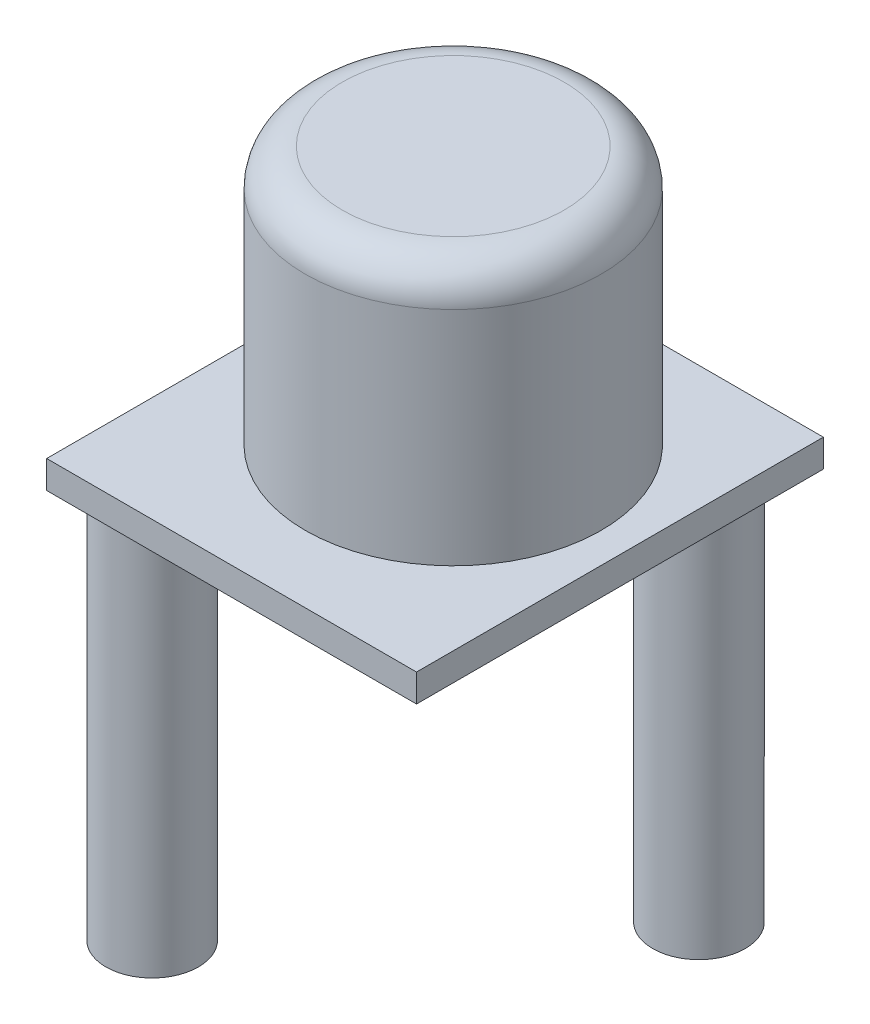
from build123d import *

# Parameters (mm, degrees)
ESBO_O1_W                = 20
ESBO_O1_H                = 22
RESSALTO_EXTRUS_O1_DEPTH = 1.5
ESBO_O2_R                = 8
RESSALTO_EXTRUS_O2_DEPTH = 14
FILETE1_R                = 2
ESBO_O3_R                = 2.5
RESSALTO_EXTRUS_O3_DEPTH = 21
ESBO_O4_W                = 8
ESBO_O4_H                = 8
RESSALTO_EXTRUS_O4_DEPTH = 10


with BuildPart() as part:
    # Esboço1 → Ressalto-extrusão1 (new body)
    with BuildSketch(Plane(origin=(0, 0, 0), x_dir=(1, 0, 0), z_dir=(0, 1, 0))):
        with Locations((-0.363033398, -2.207136461)):
            Rectangle(ESBO_O1_W, ESBO_O1_H)
    extrude(amount=RESSALTO_EXTRUS_O1_DEPTH)

    # Esboço2 → Ressalto-extrusão2 (add)
    with BuildSketch(Plane(origin=(0, 1.5, 0), x_dir=(1, 0, 0), z_dir=(0, 1, 0))):
        with Locations((0, -1.584818961)):
            Circle(ESBO_O2_R)
    extrude(amount=RESSALTO_EXTRUS_O2_DEPTH)

    # Filete1
    filete1_edges = [part.edges().sort_by_distance(p)[0] for p in [
        (-8, 15.5, 1.584818961),
    ]]
    fillet(filete1_edges, radius=FILETE1_R)

    # Esboço3 → Ressalto-extrusão3 (add)
    with BuildSketch(Plane(origin=(0, 0, 0), x_dir=(-1, 0, 0), z_dir=(0, -1, 0))):
        with Locations((7.446149428, -10.420452969)):
            Circle(ESBO_O3_R)
        with Locations((-6.479235285, 5.224259997)):
            Circle(ESBO_O3_R)
    extrude(amount=RESSALTO_EXTRUS_O3_DEPTH)

    # Esboço4 → Ressalto-extrusão4 (add)
    with BuildSketch(Plane(origin=(0, 0, 0), x_dir=(-1, 0, 0), z_dir=(0, -1, 0))):
        with Locations((4.363033398, 0.792863539)):
            Rectangle(ESBO_O4_W, ESBO_O4_H)
    extrude(amount=RESSALTO_EXTRUS_O4_DEPTH)


solid = part.part
